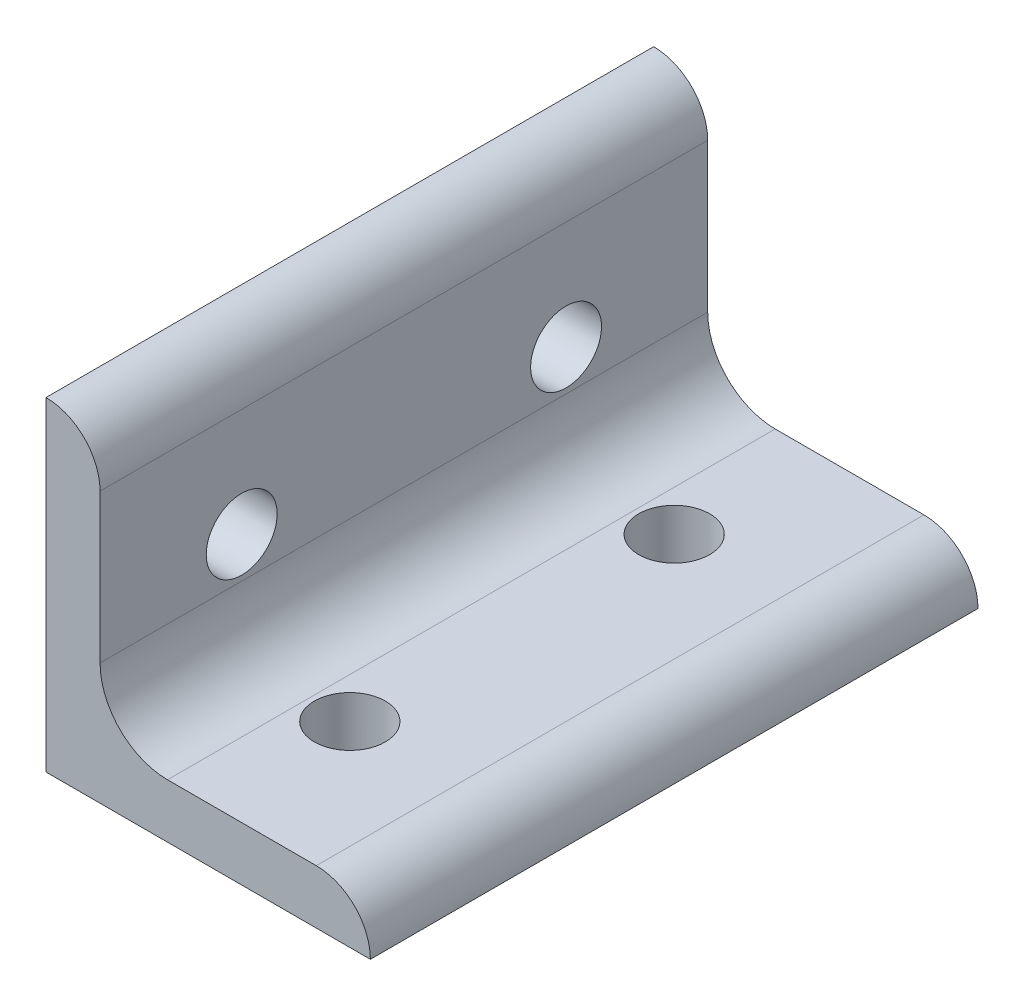
from build123d import *

# Parameters (mm, degrees)
BOSS_EXTRUDE1_DEPTH      = 35.687
BOSS_EXTRUDE1_DEPTH_BACK = 35.687
SKETCH3_R                = 4.1656
CUT_EXTRUDE1_DEPTH       = 39.1
SKETCH5_R                = 4.1656
CUT_EXTRUDE2_DEPTH       = 39.1


with BuildPart() as part:
    # Sketch4 → Boss-Extrude1 (new body, two sides)
    with BuildSketch(Plane.XY) as boss_extrude1_sk:
        with BuildLine():
            Line((38.1, 0), (0, 0))
            Line((0, 0), (0, 38.1))
            ThreePointArc((0, 38.1), (4.490128061, 36.240128061), (6.35, 31.75))
            Line((6.35, 31.75), (6.35, 14.2748))
            ThreePointArc((6.35, 14.2748), (8.67112018, 8.67112018), (14.2748, 6.35))
            Line((14.2748, 6.35), (31.75, 6.35))
            ThreePointArc((31.75, 6.35), (36.240128061, 4.490128061), (38.1, 0))
        make_face()
    extrude(amount=BOSS_EXTRUDE1_DEPTH)
    extrude(boss_extrude1_sk.sketch, amount=-BOSS_EXTRUDE1_DEPTH_BACK)

    # Sketch3 → Cut-Extrude1 (cut, through all)
    with BuildSketch(Plane(origin=(0, 0, 0), x_dir=(1, 0, 0), z_dir=(0, 1, 0))):
        with Locations((19.05, -19.05)):
            Circle(SKETCH3_R)
        with Locations((19.05, 19.05)):
            Circle(SKETCH3_R)
    extrude(amount=CUT_EXTRUDE1_DEPTH, mode=Mode.SUBTRACT)

    # Sketch5 → Cut-Extrude2 (cut, through all)
    with BuildSketch(Plane(origin=(0, 0, 0), x_dir=(0, 0, -1), z_dir=(1, 0, 0))):
        with Locations((-19.05, 19.05)):
            Circle(SKETCH5_R)
        with Locations((19.05, 19.05)):
            Circle(SKETCH5_R)
    extrude(amount=CUT_EXTRUDE2_DEPTH, mode=Mode.SUBTRACT)


solid = part.part
